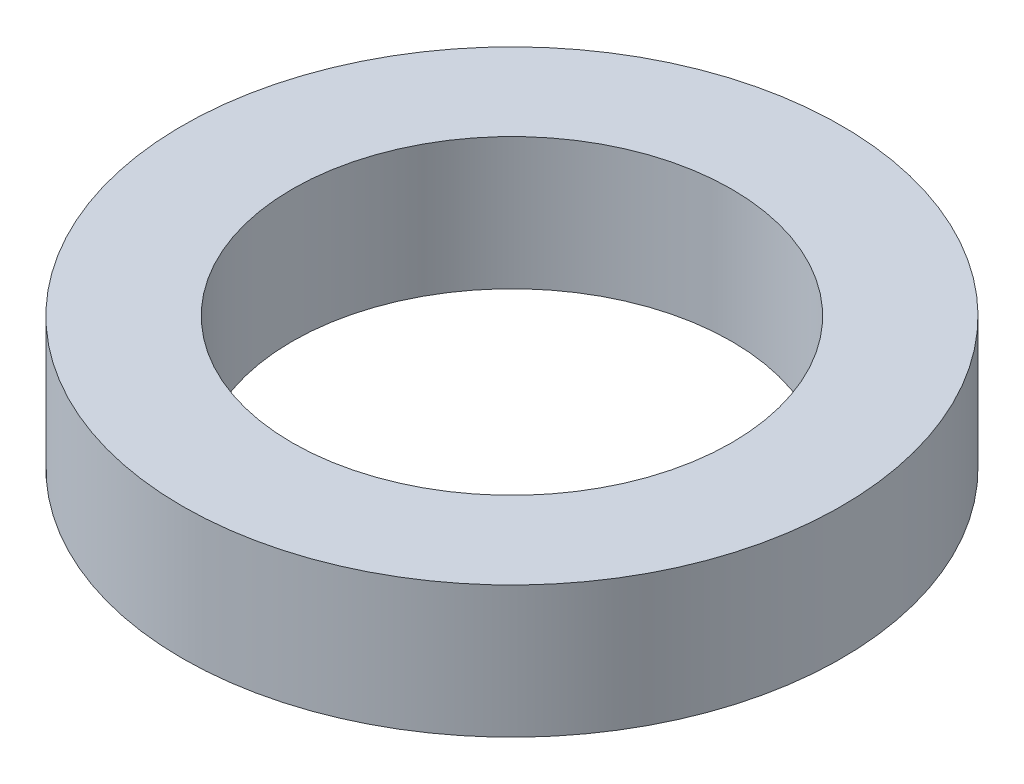
from build123d import *

# Parameters (mm, degrees)
SKETCH1_R           = 7.5
SKETCH1_R_2         = 5
BOSS_EXTRUDE1_DEPTH = 3


with BuildPart() as part:
    # Sketch1 → Boss-Extrude1 (new body)
    with BuildSketch(Plane(origin=(0, 0, 0), x_dir=(1, 0, 0), z_dir=(0, 1, 0))):
        Circle(SKETCH1_R)
        Circle(SKETCH1_R_2, mode=Mode.SUBTRACT)
    extrude(amount=BOSS_EXTRUDE1_DEPTH)


solid = part.part
